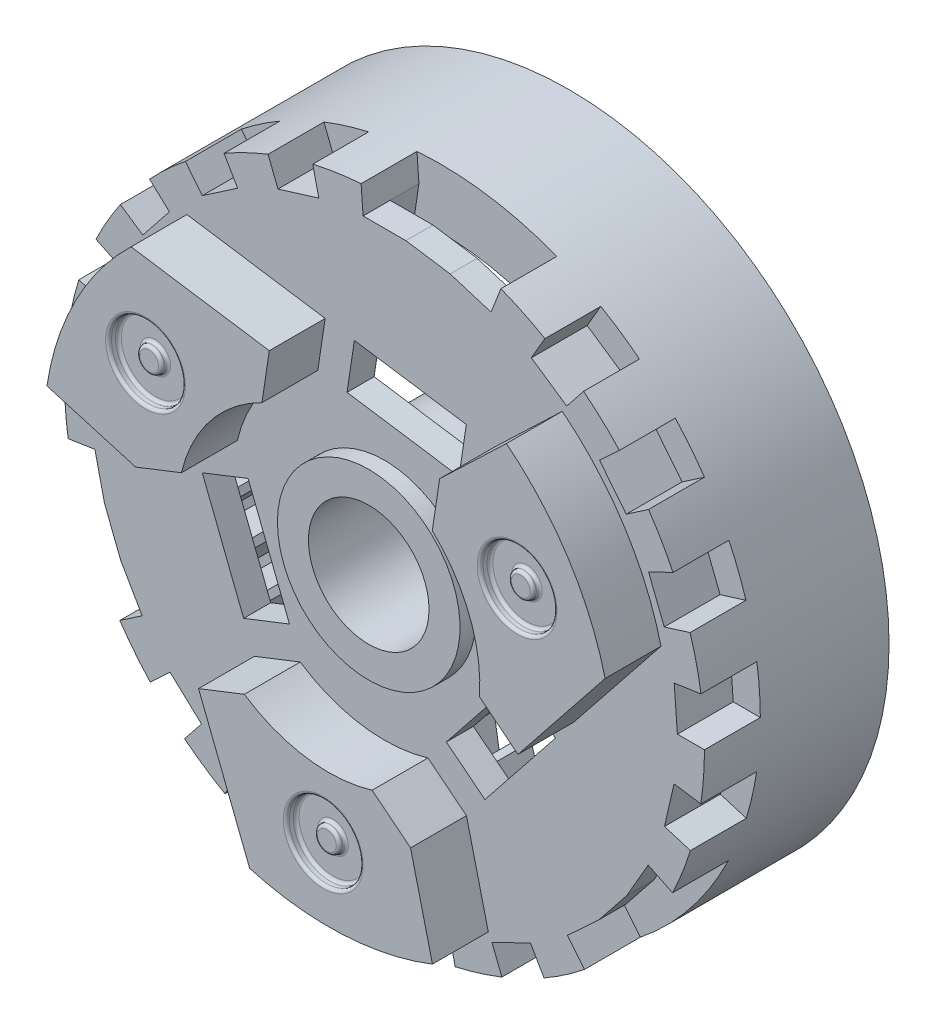
from build123d import *
from build123d.topology import SkipClean

# Parameters (mm, degrees)
SKETCH1_R                = 13
SKETCH1_R_2              = 10.6
BOSS_EXTRUDE1_DEPTH      = 7.5
SKETCH1_3_R              = 10.6
CUT_EXTRUDE1_DEPTH       = 6.4
CUT_EXTRUDE2_DEPTH       = 4.35
SKETCH3_R                = 3.71
SKETCH3_R_2              = 2.45
BOSS_EXTRUDE2_DEPTH      = 6.9
SKETCH3_2_R              = 2.45
CUT_EXTRUDE3_DEPTH       = 20.636954957
BOSS_EXTRUDE3_START      = -1.1
SKETCH3_3_R              = 3.71
SKETCH3_3_R_2            = 2.45
BOSS_EXTRUDE3_DEPTH      = 0.64
SKETCH4_R                = 15.823916771
SKETCH4_R_2              = 13
CUT_EXTRUDE4_DEPTH       = 2.27
CUT_EXTRUDE5_DEPTH       = 2.27
SKETCH6_W                = 5.257526796
SKETCH6_H                = 1.17
CUT_EXTRUDE6_DEPTH       = 2.27
CIRPATTERN1_COUNT        = 3
CUT_EXTRUDE7_DEPTH       = 21.049937656
CIRPATTERN2_COUNT        = 3
BOSS_EXTRUDE4_DEPTH      = 2.27
SKETCH9_R                = 1.5
SKETCH9_R_2              = 0.5
CUT_EXTRUDE8_DEPTH       = 0.4
SKETCH9_3_R              = 0.5
CUT_EXTRUDE9_DEPTH       = 0.15
FILLET1_R                = 0.12
CIRPATTERN3_COUNT        = 3
FILLET1_OF_CIRPATTERN3_R = 0.12


with BuildPart() as part:
    # Sketch1 → Boss-Extrude1 (new body)
    with BuildSketch(Plane.XY):
        Circle(SKETCH1_R)
        Circle(SKETCH1_R_2, mode=Mode.SUBTRACT)
        Circle(SKETCH1_R_2)
    extrude(amount=BOSS_EXTRUDE1_DEPTH)

    # Sketch1_3 → Cut-Extrude1 (cut)
    with BuildSketch(Plane.XY):
        Circle(SKETCH1_3_R)
    extrude(amount=CUT_EXTRUDE1_DEPTH, mode=Mode.SUBTRACT)

    # Sketch2 → Cut-Extrude2 (cut)
    with BuildSketch(Plane(origin=(0, 0, 0), x_dir=(-1, 0, 0), z_dir=(0, 0, -1))):
        Polygon((1.540432405, 10.713942709), (2.256903514, 11.786149097), (2.550047574, 11.72237951), (2.756361988, 10.449433419), (3.049506048, 10.385663832), (3.911275393, 11.344992234), (4.19236031, 11.240152981), (4.215415624, 9.950802043), (4.496500542, 9.845962789), (5.486024984, 10.672884047), (5.749328681, 10.529109351), (5.588655555, 9.249601033), (5.851959252, 9.105826337), (6.949094927, 9.783506718), (7.189257299, 9.603723418), (6.848126575, 8.36010482), (7.088288947, 8.18032152), (8.270701337, 8.694965405), (8.482833371, 8.482833371), (7.968189486, 7.300420981), (8.18032152, 7.088288947), (9.423940118, 7.429419671), (9.603723418, 7.189257299), (8.926043037, 6.092121624), (9.105826337, 5.851959252), (10.385334655, 6.012632378), (10.529109351, 5.749328681), (9.702188093, 4.759804239), (9.845962789, 4.496500542), (11.135313727, 4.473445228), (11.240152981, 4.19236031), (10.280824578, 3.330590965), (10.385663832, 3.049506048), (11.658609923, 2.843191634), (11.72237951, 2.550047574), (10.650173122, 1.833576464), (10.713942709, 1.540432405), (11.944570442, 1.155058857), (11.965972197, 0.855823222), (10.802714854, 0.299235634), (10.824116609, 0), (11.987373952, -0.556587588), (11.965972197, -0.855823222), (10.735344464, -1.24119677), (10.713942709, -1.540432405), (11.786149097, -2.256903514), (11.72237951, -2.550047574), (10.449433419, -2.756361988), (10.385663832, -3.049506048), (11.344992234, -3.911275393), (11.240152981, -4.19236031), (9.950802043, -4.215415624), (9.845962789, -4.496500542), (10.672884047, -5.486024984), (10.529109351, -5.749328681), (9.249601033, -5.588655555), (9.105826337, -5.851959252), (9.783506718, -6.949094927), (9.603723418, -7.189257299), (8.36010482, -6.848126575), (8.18032152, -7.088288947), (8.694965405, -8.270701337), (8.482833371, -8.482833371), (7.300420981, -7.968189486), (7.088288947, -8.18032152), (7.429419671, -9.423940118), (7.189257299, -9.603723418), (6.092121624, -8.926043037), (5.851959252, -9.105826337), (6.012632378, -10.385334655), (5.749328681, -10.529109351), (4.759804239, -9.702188093), (4.496500542, -9.845962789), (4.473445228, -11.135313727), (4.19236031, -11.240152981), (3.330590965, -10.280824578), (3.049506048, -10.385663832), (2.843191634, -11.658609923), (2.550047574, -11.72237951), (1.833576464, -10.650173122), (1.540432405, -10.713942709), (1.155058857, -11.944570442), (0.855823222, -11.965972197), (0.299235634, -10.802714854), (0, -10.824116609), (-0.556587588, -11.987373952), (-0.855823222, -11.965972197), (-1.24119677, -10.735344464), (-1.540432405, -10.713942709), (-2.256903514, -11.786149097), (-2.550047574, -11.72237951), (-2.756361988, -10.449433419), (-3.049506048, -10.385663832), (-3.911275393, -11.344992234), (-4.19236031, -11.240152981), (-4.215415624, -9.950802043), (-4.496500542, -9.845962789), (-5.486024984, -10.672884047), (-5.749328681, -10.529109351), (-5.588655555, -9.249601033), (-5.851959252, -9.105826337), (-6.949094927, -9.783506718), (-7.189257299, -9.603723418), (-6.848126575, -8.36010482), (-7.088288947, -8.18032152), (-8.270701337, -8.694965405), (-8.482833371, -8.482833371), (-7.968189486, -7.300420981), (-8.18032152, -7.088288947), (-9.423940118, -7.429419671), (-9.603723418, -7.189257299), (-8.926043037, -6.092121624), (-9.105826337, -5.851959252), (-10.385334655, -6.012632378), (-10.529109351, -5.749328681), (-9.702188093, -4.759804239), (-9.845962789, -4.496500542), (-11.135313727, -4.473445228), (-11.240152981, -4.19236031), (-10.280824578, -3.330590965), (-10.385663832, -3.049506048), (-11.658609923, -2.843191634), (-11.72237951, -2.550047574), (-10.650173122, -1.833576464), (-10.713942709, -1.540432405), (-11.944570442, -1.155058857), (-11.965972197, -0.855823222), (-10.802714854, -0.299235634), (-10.824116609, 0), (-11.987373952, 0.556587588), (-11.965972197, 0.855823222), (-10.735344464, 1.24119677), (-10.713942709, 1.540432405), (-11.786149097, 2.256903514), (-11.72237951, 2.550047574), (-10.449433419, 2.756361988), (-10.385663832, 3.049506048), (-11.344992234, 3.911275393), (-11.240152981, 4.19236031), (-9.950802043, 4.215415624), (-9.845962789, 4.496500542), (-10.672884047, 5.486024984), (-10.529109351, 5.749328681), (-9.249601033, 5.588655555), (-9.105826337, 5.851959252), (-9.783506718, 6.949094927), (-9.603723418, 7.189257299), (-8.36010482, 6.848126575), (-8.18032152, 7.088288947), (-8.694965405, 8.270701337), (-8.482833371, 8.482833371), (-7.300420981, 7.968189486), (-7.088288947, 8.18032152), (-7.429419671, 9.423940118), (-7.189257299, 9.603723418), (-6.092121624, 8.926043037), (-5.851959252, 9.105826337), (-6.012632378, 10.385334655), (-5.749328681, 10.529109351), (-4.759804239, 9.702188093), (-4.496500542, 9.845962789), (-4.473445228, 11.135313727), (-4.19236031, 11.240152981), (-3.330590965, 10.280824578), (-3.049506048, 10.385663832), (-2.843191634, 11.658609923), (-2.550047574, 11.72237951), (-1.833576464, 10.650173122), (-1.540432405, 10.713942709), (-1.155058857, 11.944570442), (-0.855823222, 11.965972197), (-0.299235634, 10.802714854), (0, 10.824116609), (0.556587588, 11.987373952), (0.855823222, 11.965972197), (1.24119677, 10.735344464), align=None)
    extrude(amount=-CUT_EXTRUDE2_DEPTH, mode=Mode.SUBTRACT)

    # Sketch3 → Boss-Extrude2 (add)
    with BuildSketch(Plane(origin=(0, 0, 6.4), x_dir=(-1, 0, 0), z_dir=(0, 0, -1))):
        with Locations(Location((0, 0, 0), (0, 0, 180))):
            Circle(SKETCH3_R)
        with Locations(Location((0, 0, 0), (0, 0, 180))):
            Circle(SKETCH3_R_2, mode=Mode.SUBTRACT)
    extrude(amount=BOSS_EXTRUDE2_DEPTH)

    # Sketch3_2 → Cut-Extrude3 (cut, through all)
    with BuildSketch(Plane(origin=(0, 0, 6.4), x_dir=(-1, 0, 0), z_dir=(0, 0, -1))):
        with Locations(Location((0, 0, 0), (0, 0, 180))):
            Circle(SKETCH3_2_R)
    extrude(amount=-CUT_EXTRUDE3_DEPTH, mode=Mode.SUBTRACT)

    # Sketch3_3 → Boss-Extrude3 (add)
    with BuildSketch(Plane(origin=(0, 0, 6.4), x_dir=(-1, 0, 0), z_dir=(0, 0, -1)).offset(BOSS_EXTRUDE3_START)):
        with Locations(Location((0, 0, 0), (0, 0, 180))):
            Circle(SKETCH3_3_R)
        with Locations(Location((0, 0, 0), (0, 0, 180))):
            Circle(SKETCH3_3_R_2, mode=Mode.SUBTRACT)
    extrude(amount=-BOSS_EXTRUDE3_DEPTH)

    # Sketch4 → Cut-Extrude4 (cut)
    with SkipClean():  # the faces are left unmerged after this step: merging them gives an invalid solid
        with BuildSketch(Plane.XY.offset(7.5)):
            Circle(SKETCH4_R)
            with Locations(Location((0, 0, 0), (0, 0, 179.905020565))):
                Circle(SKETCH4_R_2, mode=Mode.SUBTRACT)
            with BuildLine():
                Line((-5.967075619, 10.295824812), (-6.518654038, 11.24753971))
                ThreePointArc((-6.518654038, 11.24753971), (-7.323160755, 10.741104066), (-8.088507709, 10.1772316))
                Line((-8.088507709, 10.1772316), (-7.404095518, 9.316081234))
                Line((-7.404095518, 9.316081234), (-5.967075619, 10.295824812))
            make_face()
            with BuildLine():
                Line((-8.73672283, 8.079583788), (-9.544319058, 8.826436071))
                ThreePointArc((-9.544319058, 8.826436071), (-10.163809272, 8.105367424), (-10.728949682, 7.340956254))
                Line((-10.728949682, 7.340956254), (-9.821115478, 6.719798418))
                Line((-9.821115478, 6.719798418), (-8.73672283, 8.079583788))
            make_face()
            with BuildLine():
                Line((-11.770010771, 1.754094194), (-12.85799496, 1.916237355))
                ThreePointArc((-12.85799496, 1.916237355), (-12.963649363, 0.971491217), (-12.999982138, 0.02155014))
                Line((-12.999982138, 0.02155014), (-11.89998365, 0.019726667))
                Line((-11.89998365, 0.019726667), (-11.770010771, 1.754094194))
            make_face()
            with BuildLine():
                Line((-11.764130557, -1.793106867), (-12.851571197, -1.958856241))
                ThreePointArc((-12.851571197, -1.958856241), (-12.674062858, -2.892772141), (-12.428781422, -3.811219274))
                Line((-12.428781422, -3.811219274), (-11.377115302, -3.48873149))
                Line((-11.377115302, -3.48873149), (-11.764130557, -1.793106867))
            make_face()
            with BuildLine():
                Line((-8.709887748, -8.108505128), (-9.515003422, -8.858030813))
                ThreePointArc((-9.515003422, -8.858030813), (-8.842245591, -9.529674334), (-8.122204866, -10.150359014))
                Line((-8.122204866, -10.150359014), (-7.434941377, -9.291482482))
                Line((-7.434941377, -9.291482482), (-8.709887748, -8.108505128))
            make_face()
            with BuildLine():
                Line((-5.93290803, -10.315551479), (-6.4813281, -11.269089851))
                ThreePointArc((-6.4813281, -11.269089851), (-5.640488609, -11.712595283), (-4.769487251, -12.093468955))
                Line((-4.769487251, -12.093468955), (-4.365915253, -11.070175428))
                Line((-4.365915253, -11.070175428), (-5.93290803, -10.315551479))
            make_face()
            with BuildLine():
                ThreePointArc((-2.871758333, -12.678840802), (-1.93754946, -12.854800741), (-0.992979764, -12.962021107))
                Line((-0.992979764, -12.962021107), (-0.908958399, -11.865234706))
                Line((-0.908958399, -11.865234706), (-2.628763398, -11.606015811))
                Line((-2.628763398, -11.606015811), (-2.871758333, -12.678840802))
            make_face()
            with BuildLine():
                ThreePointArc((0.992979764, -12.962021107), (1.93754946, -12.854800741), (2.871758333, -12.678840802))
                Line((2.871758333, -12.678840802), (2.628763398, -11.606015811))
                Line((2.628763398, -11.606015811), (0.908958399, -11.865234706))
                Line((0.908958399, -11.865234706), (0.992979764, -12.962021107))
            make_face()
            with BuildLine():
                ThreePointArc((4.769487251, -12.093468955), (5.640488609, -11.712595283), (6.4813281, -11.269089851))
                Line((6.4813281, -11.269089851), (5.93290803, -10.315551479))
                Line((5.93290803, -10.315551479), (4.365915253, -11.070175428))
                Line((4.365915253, -11.070175428), (4.769487251, -12.093468955))
            make_face()
            with BuildLine():
                ThreePointArc((8.122204866, -10.150359014), (8.842245591, -9.529674334), (9.515003422, -8.858030813))
                Line((9.515003422, -8.858030813), (8.709887748, -8.108505128))
                Line((8.709887748, -8.108505128), (7.434941377, -9.291482482))
                Line((7.434941377, -9.291482482), (8.122204866, -10.150359014))
            make_face()
            with BuildLine():
                ThreePointArc((12.428781422, -3.811219274), (12.674062858, -2.892772141), (12.851571197, -1.958856241))
                Line((12.851571197, -1.958856241), (11.764130557, -1.793106867))
                Line((11.764130557, -1.793106867), (11.377115302, -3.48873149))
                Line((11.377115302, -3.48873149), (12.428781422, -3.811219274))
            make_face()
            with BuildLine():
                ThreePointArc((12.999982138, 0.02155014), (12.963649363, 0.971491217), (12.85799496, 1.916237355))
                Line((12.85799496, 1.916237355), (11.770010771, 1.754094194))
                Line((11.770010771, 1.754094194), (11.89998365, 0.019726667))
                Line((11.89998365, 0.019726667), (12.999982138, 0.02155014))
            make_face()
            with BuildLine():
                ThreePointArc((10.728949682, 7.340956254), (10.163809272, 8.105367424), (9.544319058, 8.826436071))
                Line((9.544319058, 8.826436071), (8.73672283, 8.079583788))
                Line((8.73672283, 8.079583788), (9.821115478, 6.719798418))
                Line((9.821115478, 6.719798418), (10.728949682, 7.340956254))
            make_face()
            with BuildLine():
                ThreePointArc((8.088507709, 10.1772316), (7.323160755, 10.741104066), (6.518654038, 11.24753971))
                Line((6.518654038, 11.24753971), (5.967075619, 10.295824812))
                Line((5.967075619, 10.295824812), (7.404095518, 9.316081234))
                Line((7.404095518, 9.316081234), (8.088507709, 10.1772316))
            make_face()
            with BuildLine():
                ThreePointArc((4.729366331, 12.109215256), (3.831817267, 12.422446475), (2.913778, 12.669250087))
                Line((2.913778, 12.669250087), (2.667227554, 11.597236618))
                Line((2.667227554, 11.597236618), (4.32918918, 11.084589349))
                Line((4.32918918, 11.084589349), (4.729366331, 12.109215256))
            make_face()
            with BuildLine():
                Line((-2.667227554, 11.597236618), (-2.913778, 12.669250087))
                ThreePointArc((-2.913778, 12.669250087), (-3.831817267, 12.422446475), (-4.729366331, 12.109215256))
                Line((-4.729366331, 12.109215256), (-4.32918918, 11.084589349))
                Line((-4.32918918, 11.084589349), (-2.667227554, 11.597236618))
            make_face()
            with BuildLine():
                ThreePointArc((12.416077392, 3.852404731), (12.101358732, 4.749433317), (11.721929445, 5.621064853))
                Line((11.721929445, 5.621064853), (10.730073877, 5.145436288))
                Line((10.730073877, 5.145436288), (11.365486228, 3.526432023))
                Line((11.365486228, 3.526432023), (12.416077392, 3.852404731))
            make_face()
            with BuildLine():
                Line((-10.730073877, 5.145436288), (-11.721929445, 5.621064853))
                ThreePointArc((-11.721929445, 5.621064853), (-12.101358732, 4.749433317), (-12.416077392, 3.852404731))
                Line((-12.416077392, 3.852404731), (-11.365486228, 3.526432023))
                Line((-11.365486228, 3.526432023), (-10.730073877, 5.145436288))
            make_face()
            with BuildLine():
                Line((0.869615385, 11.868183057), (0.95, 12.965241995))
                ThreePointArc((0.95, 12.965241995), (0, 13), (-0.95, 12.965241995))
                Line((-0.95, 12.965241995), (-0.869615385, 11.868183057))
                Line((-0.869615385, 11.868183057), (0.869615385, 11.868183057))
            make_face()
            with BuildLine():
                ThreePointArc((10.753228934, -7.305345131), (11.258330249, -6.5), (11.703228934, -5.659896864))
                Line((11.703228934, -5.659896864), (10.712955717, -5.180982514))
                Line((10.712955717, -5.180982514), (9.843340332, -6.687200543))
                Line((9.843340332, -6.687200543), (10.753228934, -7.305345131))
            make_face()
            with BuildLine():
                Line((-10.712955717, -5.180982514), (-11.703228934, -5.659896864))
                ThreePointArc((-11.703228934, -5.659896864), (-11.258330249, -6.5), (-10.753228934, -7.305345131))
                Line((-10.753228934, -7.305345131), (-9.843340332, -6.687200543))
                Line((-9.843340332, -6.687200543), (-10.712955717, -5.180982514))
            make_face()
        extrude(amount=-CUT_EXTRUDE4_DEPTH, mode=Mode.SUBTRACT)

    # Sketch5 → Cut-Extrude5 (cut)
    with SkipClean():  # the faces are left unmerged after this step: merging them gives an invalid solid
        with BuildSketch(Plane.XY.offset(7.5)):
            with BuildLine():
                Line((2.913778, 12.669250087), (2.667227554, 11.597236618))
                Line((2.667227554, 11.597236618), (0.869615385, 11.868183057))
                Line((0.869615385, 11.868183057), (0.95, 12.965241995))
                ThreePointArc((0.95, 12.965241995), (1.93754946, 12.854800741), (2.913778, 12.669250087))
            make_face()
        cut_extrude5 = extrude(amount=-CUT_EXTRUDE5_DEPTH, mode=Mode.SUBTRACT)

    # Sketch6 → Cut-Extrude6 (cut)
    with SkipClean():  # the faces are left unmerged after this step: merging them gives an invalid solid
        with BuildSketch(Plane(origin=(1.768421469, 11.732709838, 0), x_dir=(0.9888308262251848, -0.14904226617580107, 0), z_dir=(0.14904226617580107, 0.9888308262251849, 0))):
            with Locations((0, -5.815)):
                Rectangle(SKETCH6_W, SKETCH6_H)
        cut_extrude6 = extrude(amount=-CUT_EXTRUDE6_DEPTH, mode=Mode.SUBTRACT)

    # CirPattern1: Cut-Extrude5, Cut-Extrude6 ×3 about axis
    with SkipClean():  # the faces are left unmerged after this step: merging them gives an invalid solid
        cirpattern1_axis = Axis((0, 0, 0), (0, 0, 1))
        add([cut_extrude5.rotate(cirpattern1_axis, i * 360 / CIRPATTERN1_COUNT) for i in range(1, CIRPATTERN1_COUNT)], mode=Mode.SUBTRACT)
        add([cut_extrude6.rotate(cirpattern1_axis, i * 360 / CIRPATTERN1_COUNT) for i in range(1, CIRPATTERN1_COUNT)], mode=Mode.SUBTRACT)

    # Sketch7 → Cut-Extrude7 (cut, through all)
    with SkipClean():  # the faces are left unmerged after this step: merging them gives an invalid solid
        with BuildSketch(Plane.XY.offset(7.5)):
            Polygon((-5.722375572, -4.716663844), (-7.402944284, -0.4346446), (-5.541196787, 0.296037449), (-3.860628075, -3.985981795), align=None)
        cut_extrude7 = extrude(amount=-CUT_EXTRUDE7_DEPTH, mode=Mode.SUBTRACT)

    # CirPattern2: Cut-Extrude7 ×3 about axis
    with SkipClean():  # the faces are left unmerged after this step: merging them gives an invalid solid
        cirpattern2_axis = Axis((0, 0, 0), (0, 0, 1))
        for i in range(1, CIRPATTERN2_COUNT):
            add(cut_extrude7.rotate(cirpattern2_axis, i * 360 / CIRPATTERN2_COUNT), mode=Mode.SUBTRACT)

    # Sketch8 → Boss-Extrude4 (add)
    with SkipClean():  # the faces are left unmerged after this step: merging them gives an invalid solid
        with BuildSketch(Plane.XY.offset(7.5)):
            with BuildLine():
                Line((-7.841353513, 0.682403898), (-5.979606016, 1.413085947))
                ThreePointArc((-5.979606016, 1.413085947), (-4.803812109, 3.830912322), (-2.708244448, 5.515243604))
                Line((-2.708244448, 5.515243604), (-2.410159915, 7.492905257))
                Line((-2.410159915, 7.492905257), (-8.026454701, 8.33942549))
                ThreePointArc((-8.026454701, 8.33942549), (-10.279695178, 5.319573256), (-11.443611699, 1.736013783))
                Line((-11.443611699, 1.736013783), (-7.841353513, 0.682403898))
            make_face()
        boss_extrude4 = extrude(amount=BOSS_EXTRUDE4_DEPTH)

    # Sketch9 → Cut-Extrude8 (cut)
    with SkipClean():  # the faces are left unmerged after this step: merging them gives an invalid solid
        with BuildSketch(Plane.XY.offset(9.77)):
            with Locations((-7.440305277, 4.54766327)):
                Circle(SKETCH9_R)
            with Locations((-7.440305277, 4.54766327)):
                Circle(SKETCH9_R_2, mode=Mode.SUBTRACT)
        cut_extrude8 = extrude(amount=-CUT_EXTRUDE8_DEPTH, mode=Mode.SUBTRACT)

    # Sketch9_3 → Cut-Extrude9 (cut)
    with SkipClean():  # the faces are left unmerged after this step: merging them gives an invalid solid
        with BuildSketch(Plane.XY.offset(9.77)):
            with Locations((-7.440305277, 4.54766327)):
                Circle(SKETCH9_3_R)
        cut_extrude9 = extrude(amount=-CUT_EXTRUDE9_DEPTH, mode=Mode.SUBTRACT)

    # Fillet1
    fillet1_edges = [part.edges().sort_by_distance(p)[0] for p in [
        (-8.940305277, 4.54766327, 9.37),
        (-7.940305277, 4.54766327, 9.37),
        (-8.940305277, 4.54766327, 9.77),
        (-7.940305277, 4.54766327, 9.62),
    ]]
    fillet(fillet1_edges, radius=FILLET1_R)

    # CirPattern3: Boss-Extrude4, Cut-Extrude8, Cut-Extrude9 ×3 about axis
    cirpattern3_axis = Axis((0, 0, 0), (0, 0, 1))
    add([boss_extrude4.rotate(cirpattern3_axis, i * 360 / CIRPATTERN3_COUNT) for i in range(1, CIRPATTERN3_COUNT)])
    add([cut_extrude8.rotate(cirpattern3_axis, i * 360 / CIRPATTERN3_COUNT) for i in range(1, CIRPATTERN3_COUNT)], mode=Mode.SUBTRACT)
    add([cut_extrude9.rotate(cirpattern3_axis, i * 360 / CIRPATTERN3_COUNT) for i in range(1, CIRPATTERN3_COUNT)], mode=Mode.SUBTRACT)

    # Fillet1 of CirPattern3
    fillet1_of_cirpattern3_edges = [part.edges().sort_by_distance(p)[0] for p in [
        (0.531760719, -10.016363123, 9.37),
        (0.031760719, -9.150337719, 9.37),
        (0.531760719, -10.016363123, 9.77),
        (0.031760719, -9.150337719, 9.62),
        (8.408544559, 5.468699853, 9.37),
        (7.908544559, 4.602674449, 9.37),
        (8.408544559, 5.468699853, 9.77),
        (7.908544559, 4.602674449, 9.62),
    ]]
    fillet(fillet1_of_cirpattern3_edges, radius=FILLET1_OF_CIRPATTERN3_R)


solid = part.part
